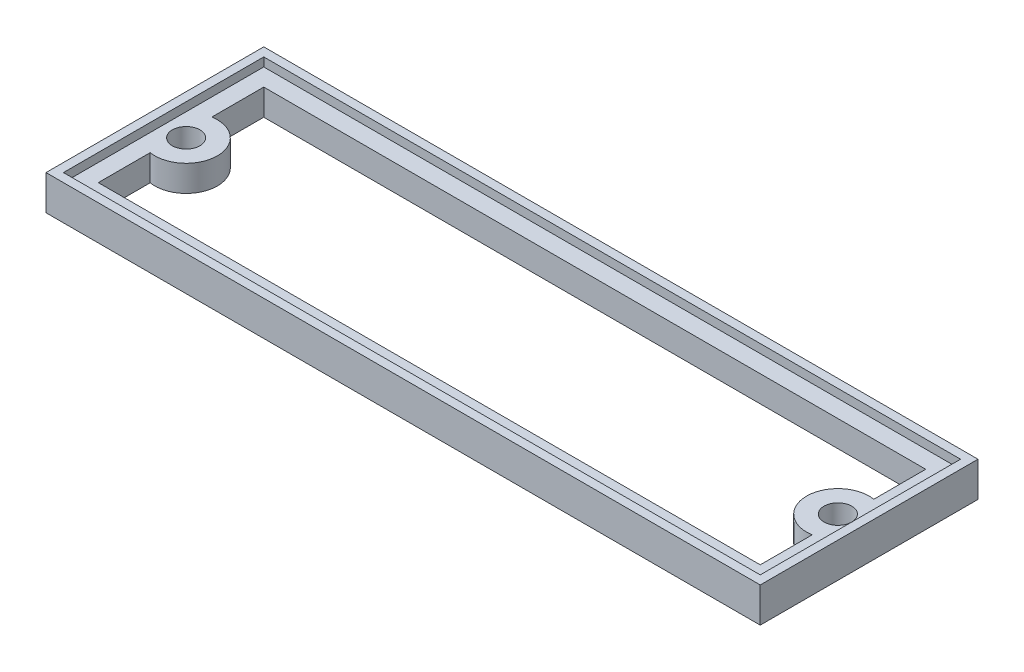
from build123d import *

# Parameters (mm, degrees)
SKETCH1_W           = 80
SKETCH1_H           = 23
SKETCH1_R           = 1.5875
BOSS_EXTRUDE1_DEPTH = 3
SKETCH1_3_W         = 82
SKETCH1_3_H         = 25
SKETCH1_3_W_2       = 80
SKETCH1_3_H_2       = 23
BOSS_EXTRUDE2_DEPTH = 4


with BuildPart() as part:
    # Sketch1 → Boss-Extrude1 (new body)
    with BuildSketch(Plane(origin=(0, 0, 0), x_dir=(1, 0, 0), z_dir=(0, 1, 0))):
        with Locations((40, 11.5)):
            Rectangle(SKETCH1_W, SKETCH1_H)
        with Locations((2.5875, 11.5)):
            Circle(SKETCH1_R, mode=Mode.SUBTRACT)
        with BuildLine():
            Line((2, 15.039067674), (2, 21))
            Line((2, 21), (78, 21))
            Line((78, 21), (78, 15.039067674))
            ThreePointArc((78, 15.039067674), (73.825, 11.5), (78, 7.960932326))
            Line((78, 7.960932326), (78, 2))
            Line((78, 2), (2, 2))
            Line((2, 2), (2, 7.960932326))
            ThreePointArc((2, 7.960932326), (6.175, 11.5), (2, 15.039067674))
        make_face(mode=Mode.SUBTRACT)
        with Locations((77.4125, 11.5)):
            Circle(SKETCH1_R, mode=Mode.SUBTRACT)
    extrude(amount=BOSS_EXTRUDE1_DEPTH)

    # Sketch1_3 → Boss-Extrude2 (add)
    with BuildSketch(Plane(origin=(0, 0, 0), x_dir=(1, 0, 0), z_dir=(0, 1, 0))):
        with Locations((40, 11.5)):
            Rectangle(SKETCH1_3_W, SKETCH1_3_H)
        with Locations((40, 11.5)):
            Rectangle(SKETCH1_3_W_2, SKETCH1_3_H_2, mode=Mode.SUBTRACT)
    extrude(amount=BOSS_EXTRUDE2_DEPTH)


solid = part.part
